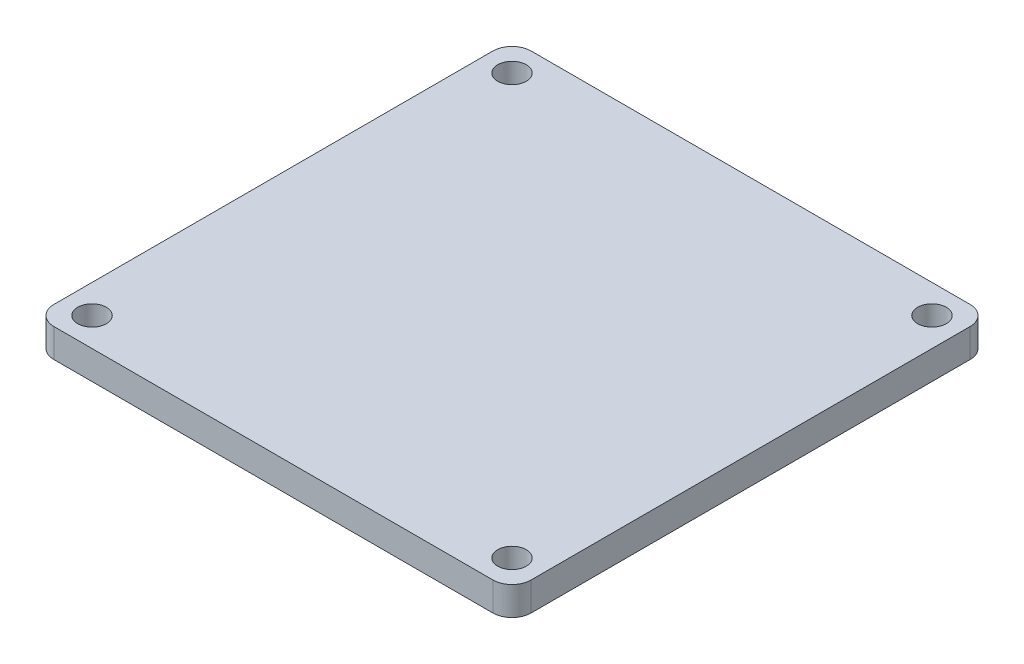
from build123d import *

# Parameters (mm, degrees)
SKETCH1_R           = 1.5
BOSS_EXTRUDE1_DEPTH = 3


with BuildPart() as part:
    # Sketch1 → Boss-Extrude1 (new body)
    with BuildSketch(Plane(origin=(0, 0, 0), x_dir=(1, 0, 0), z_dir=(0, 1, 0))):
        with BuildLine():
            Line((23, 25), (-23, 25))
            ThreePointArc((-23, 25), (-24.414213562, 24.414213562), (-25, 23))
            Line((-25, 23), (-25, -23))
            ThreePointArc((-25, -23), (-24.414213562, -24.414213562), (-23, -25))
            Line((-23, -25), (23, -25))
            ThreePointArc((23, -25), (24.414213562, -24.414213562), (25, -23))
            Line((25, -23), (25, 23))
            ThreePointArc((25, 23), (24.414213562, 24.414213562), (23, 25))
        make_face()
        with Locations((22, 22)):
            Circle(SKETCH1_R, mode=Mode.SUBTRACT)
        with Locations((22, -22)):
            Circle(SKETCH1_R, mode=Mode.SUBTRACT)
        with Locations((-22, 22)):
            Circle(SKETCH1_R, mode=Mode.SUBTRACT)
        with Locations((-22, -22)):
            Circle(SKETCH1_R, mode=Mode.SUBTRACT)
    extrude(amount=BOSS_EXTRUDE1_DEPTH)


solid = part.part
